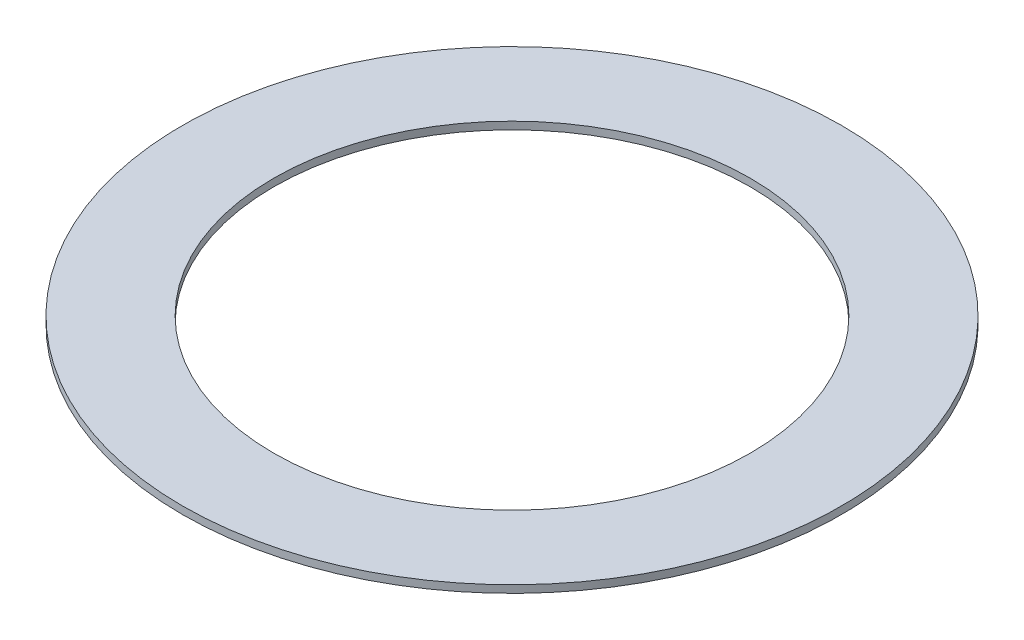
from build123d import *

# Parameters (mm, degrees)
SKETCH1_R           = 105.41
SKETCH1_R_2         = 76.2
BOSS_EXTRUDE1_DEPTH = 2.4


with BuildPart() as part:
    # Sketch1 → Boss-Extrude1 (new body)
    with BuildSketch(Plane(origin=(0, 0, 0), x_dir=(1, 0, 0), z_dir=(0, 1, 0))):
        Circle(SKETCH1_R)
        Circle(SKETCH1_R_2, mode=Mode.SUBTRACT)
    extrude(amount=BOSS_EXTRUDE1_DEPTH)


solid = part.part
